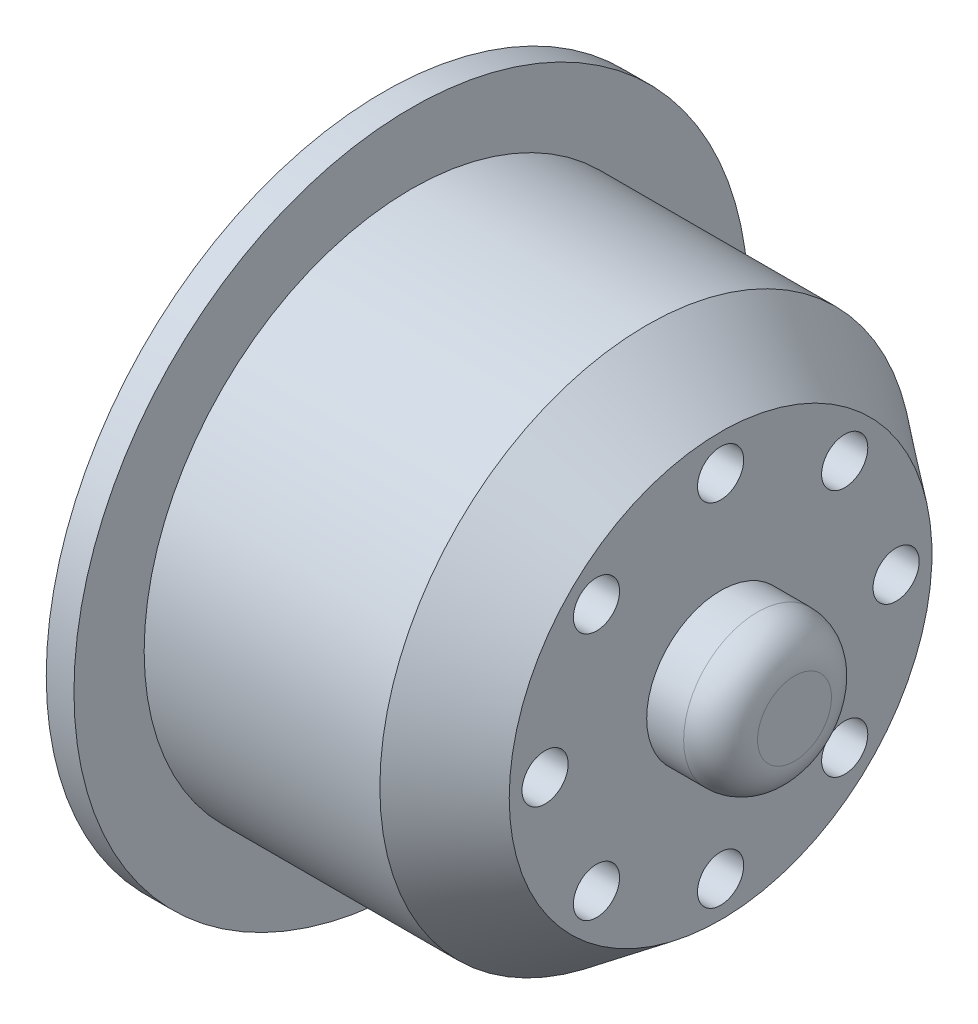
from build123d import *

# Parameters (mm, degrees)
SKETCH2_R          = 1.25
CUT_EXTRUDE1_DEPTH = 19.25
FILLET1_R          = 2
SKETCH3_R          = 2.5
CUT_EXTRUDE2_DEPTH = 13.25
SKETCH4_R          = 4.65
CUT_EXTRUDE3_DEPTH = 10


with BuildPart() as part:
    # Sketch1 → Revolve1 (revolve)
    with BuildSketch(Plane(origin=(0, 0, 0), x_dir=(1, 0, 0), z_dir=(0, 1, 0))):
        Polygon((-6.130434783, 14.45), (6.626387667, 14.45), (10.619565217, 11.440924884), (10.619565217, 4), (14.619565217, 4), (14.619565217, 0), (13.372742768, 0), (-6.130434783, 0), (-7.630434783, 0), (-7.630434783, 18.25), (-6.130434783, 18.25), align=None)
    revolve(axis=Axis((-12.391304348, 0, 0), (1, 0, 0)))

    # Sketch2 → Cut-Extrude1 (cut, through all)
    with BuildSketch(Plane(origin=(10.619565217, 0, 0), x_dir=(0, 0, -1), z_dir=(1, 0, 0))):
        with Locations((0, 9.5)):
            Circle(SKETCH2_R)
        with Locations((6.717514421, 6.717514421)):
            Circle(SKETCH2_R)
        with Locations((9.5, 0)):
            Circle(SKETCH2_R)
        with Locations((6.717514421, -6.717514421)):
            Circle(SKETCH2_R)
        with Locations((0, -9.5)):
            Circle(SKETCH2_R)
        with Locations((-6.717514421, -6.717514421)):
            Circle(SKETCH2_R)
        with Locations((-9.5, 0)):
            Circle(SKETCH2_R)
        with Locations((-6.717514421, 6.717514421)):
            Circle(SKETCH2_R)
    extrude(amount=-CUT_EXTRUDE1_DEPTH, mode=Mode.SUBTRACT)

    # Fillet1
    fillet1_edges = [part.edges().sort_by_distance(p)[0] for p in [
        (14.619565217, 0, 4),
    ]]
    fillet(fillet1_edges, radius=FILLET1_R)

    # Sketch3 → Cut-Extrude2 (cut)
    with BuildSketch(Plane.ZY.offset(7.630434783)):
        with Locations((0, 9.5)):
            Circle(SKETCH3_R)
        with Locations((6.717514421, 6.717514421)):
            Circle(SKETCH3_R)
        with Locations((9.5, 0)):
            Circle(SKETCH3_R)
        with Locations((6.717514421, -6.717514421)):
            Circle(SKETCH3_R)
        with Locations((0, -9.5)):
            Circle(SKETCH3_R)
        with Locations((-6.717514421, -6.717514421)):
            Circle(SKETCH3_R)
        with Locations((-9.5, 0)):
            Circle(SKETCH3_R)
        with Locations((-6.717514421, 6.717514421)):
            Circle(SKETCH3_R)
    extrude(amount=-CUT_EXTRUDE2_DEPTH, mode=Mode.SUBTRACT)

    # Sketch4 → Cut-Extrude3 (cut)
    with BuildSketch(Plane.ZY.offset(7.630434783)):
        Circle(SKETCH4_R)
    extrude(amount=-CUT_EXTRUDE3_DEPTH, mode=Mode.SUBTRACT)


solid = part.part
